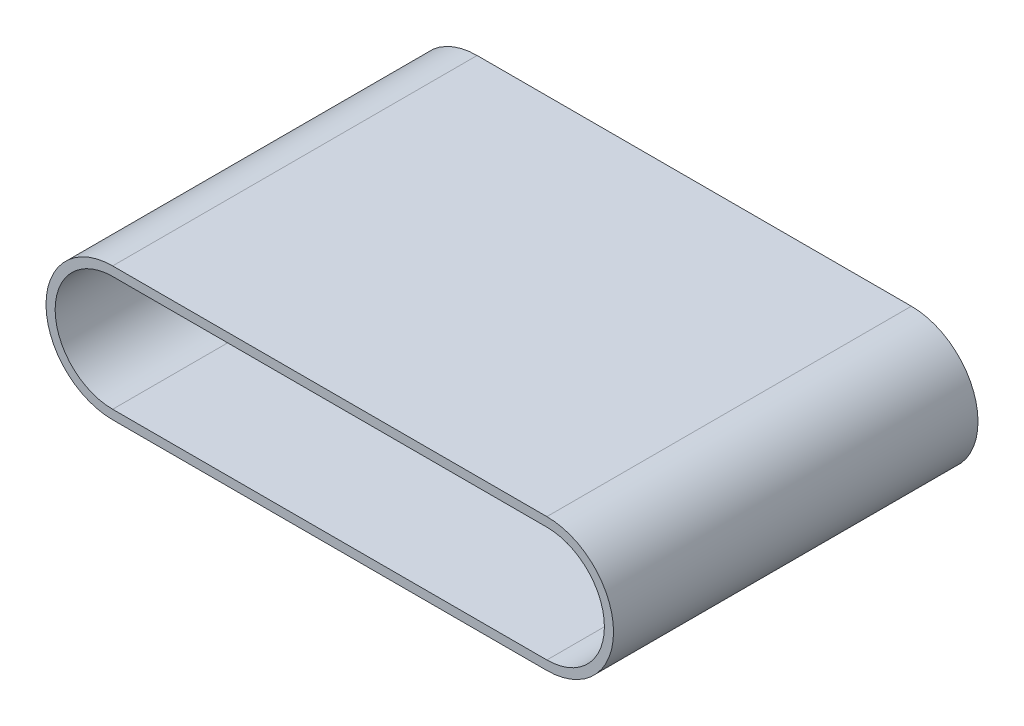
from build123d import *

# Parameters (mm, degrees)
BOSS_EXTRUDE1_DEPTH = 7
BOSS_EXTRUDE3_DEPTH = 5


with BuildPart() as part:
    # Sketch1 → Boss-Extrude1 (new body)
    with BuildSketch(Plane.XY):
        with BuildLine():
            Line((0, 1.28), (8.34, 1.28))
            ThreePointArc((8.34, 1.28), (9.62, 0), (8.34, -1.28))
            Line((8.34, -1.28), (0, -1.28))
            ThreePointArc((0, -1.28), (-1.28, 0), (0, 1.28))
        make_face()
        with BuildLine():
            Line((0, 1.1044516), (8.34, 1.1044516))
            ThreePointArc((8.34, 1.1044516), (9.4444516, 0), (8.34, -1.1044516))
            Line((8.34, -1.1044516), (0, -1.1044516))
            ThreePointArc((0, -1.1044516), (-1.1044516, 0), (0, 1.1044516))
        make_face(mode=Mode.SUBTRACT)
    extrude(amount=BOSS_EXTRUDE1_DEPTH)


with BuildPart() as body_2:
    # Sketch2 → Boss-Extrude3 (new body)
    with BuildSketch(Plane(origin=(0, 0, 0), x_dir=(-1, 0, 0), z_dir=(0, 0, -1))):
        with BuildLine():
            Line((0, -0.159919522), (-8.350175881, -0.159919522))
            ThreePointArc((-8.350175881, -0.159919522), (-8.510095402, 0), (-8.350175881, 0.159919522))
            Line((-8.350175881, 0.159919522), (0, 0.159919522))
            ThreePointArc((0, 0.159919522), (0.159919522, 0), (0, -0.159919522))
        make_face()
    extrude(amount=-BOSS_EXTRUDE3_DEPTH)


solid = Compound([part.part, body_2.part])
